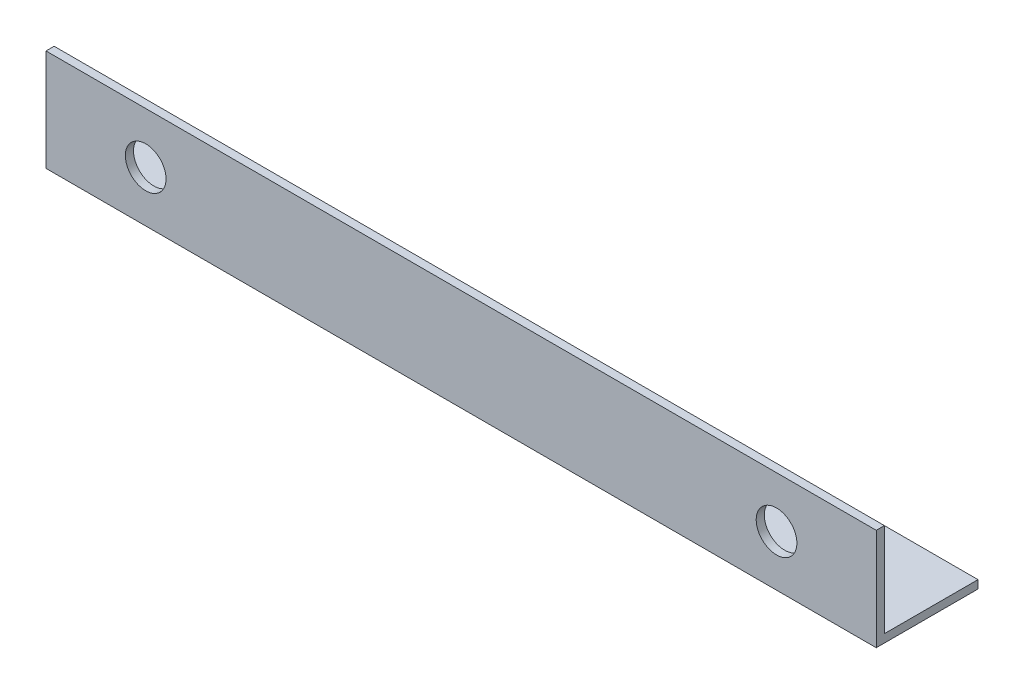
from build123d import *

# Parameters (mm, degrees)
EXTRUDE_1_DEPTH     = 204
SKETCH_2_R          = 5
CUT_EXTRUDE_1_DEPTH = 26


with BuildPart() as part:
    # Эскиз1 → Вытянуть-Тонкостенный1 (new body)
    with BuildSketch(Plane(origin=(0, 0, 0), x_dir=(0, 0, -1), z_dir=(1, 0, 0))):
        Polygon((0, 25), (0, 0), (25, 0), (25, 2), (2, 2), (2, 25), align=None)
    extrude(amount=EXTRUDE_1_DEPTH)

    # Эскиз2 → Вырез-Вытянуть1 (cut, through all)
    with BuildSketch(Plane.XY):
        with Locations((24.5, 12.5)):
            Circle(SKETCH_2_R)
        with Locations((179.5, 12.5)):
            Circle(SKETCH_2_R)
    extrude(amount=-CUT_EXTRUDE_1_DEPTH, mode=Mode.SUBTRACT)


solid = part.part
